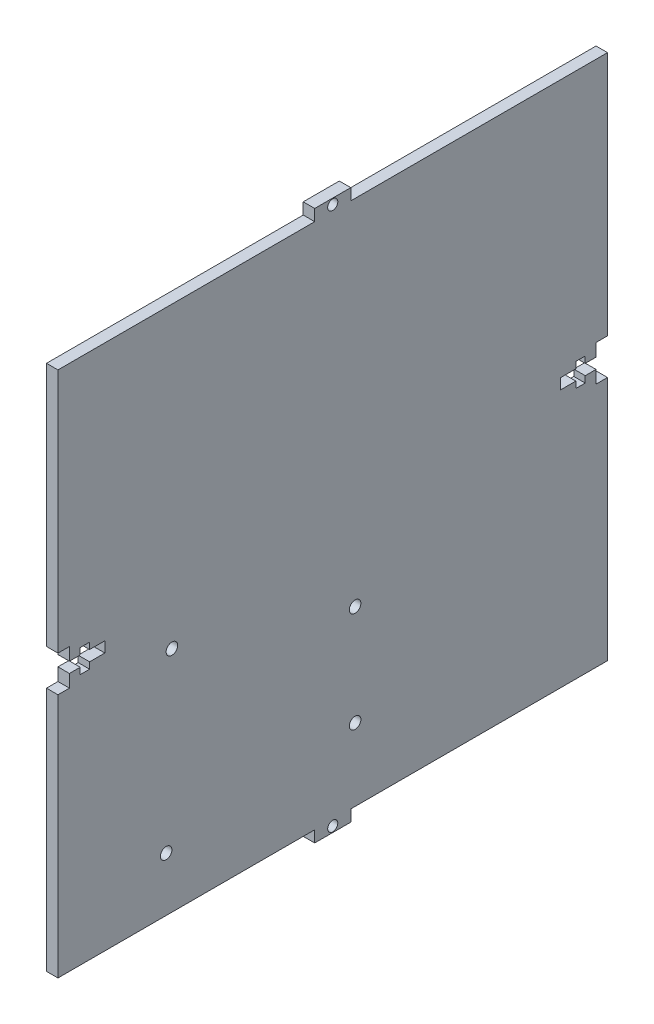
from build123d import *

# Parameters (mm, degrees)
SKETCH1_W           = 152.4
SKETCH1_H           = 146.04
BOSS_EXTRUDE1_DEPTH = 3.18
SKETCH3_R           = 1.4
SKETCH3_W           = 10
SKETCH3_H           = 3.18
BOSS_EXTRUDE5_DEPTH = 3.18
CUT_EXTRUDE2_DEPTH  = 4.18
CUT_EXTRUDE3_DEPTH  = 4.18
SKETCH6_R           = 1.6
CUT_EXTRUDE6_DEPTH  = 4.18


with BuildPart() as part:
    # Sketch1 → Boss-Extrude1 (new body)
    with BuildSketch(Plane(origin=(0, 0, 0), x_dir=(0, 0, -1), z_dir=(1, 0, 0))):
        Rectangle(SKETCH1_W, SKETCH1_H)
    extrude(amount=BOSS_EXTRUDE1_DEPTH)

    # Sketch3 → Boss-Extrude5 (add)
    with BuildSketch(Plane.ZY):
        Polygon((0, 73.02), (5, 73.02), (5, 76.2), (-5, 76.2), (-5, 73.02), align=None)
        with Locations((0, 74.61)):
            Circle(SKETCH3_R, mode=Mode.SUBTRACT)
        with Locations((0, -74.61)):
            Rectangle(SKETCH3_W, SKETCH3_H)
        with Locations((0, -74.61)):
            Circle(SKETCH3_R, mode=Mode.SUBTRACT)
    extrude(amount=-BOSS_EXTRUDE5_DEPTH)

    # Sketch4 → Cut-Extrude2 (cut, through all)
    with BuildSketch(Plane(origin=(0, 0, 0), x_dir=(0, 0, -1), z_dir=(1, 0, 0))):
        Polygon((-76.2, -5), (-76.2, 5), (-73.02, 5), (-73.02, 1.47), (-70.02, 1.47), (-70.02, 3.25), (-67.42, 3.25), (-67.42, 1.47), (-63.2, 1.47), (-63.2, -1.47), (-67.42, -1.47), (-67.42, -3.25), (-70.02, -3.25), (-70.02, -1.47), (-73.02, -1.47), (-73.02, -5), align=None)
    extrude(amount=CUT_EXTRUDE2_DEPTH, mode=Mode.SUBTRACT)

    # Sketch5 → Cut-Extrude3 (cut, through all)
    with BuildSketch(Plane.ZY):
        Polygon((-70.02, -1.47), (-73.02, -1.47), (-73.02, -5), (-76.2, -5), (-76.2, 5), (-73.02, 5), (-73.02, 1.47), (-70.02, 1.47), (-70.02, 3.25), (-67.42, 3.25), (-67.42, 1.47), (-63.2, 1.47), (-63.2, -1.47), (-67.42, -1.47), (-67.42, -3.25), (-70.02, -3.25), align=None)
    extrude(amount=-CUT_EXTRUDE3_DEPTH, mode=Mode.SUBTRACT)

    # Sketch6 → Cut-Extrude6 (cut, through all)
    with BuildSketch(Plane.ZY):
        with Locations((46.2, -58.02)):
            Circle(SKETCH6_R)
        with Locations((44.6, -9.72)):
            Circle(SKETCH6_R)
        with Locations((-6.2, -52.92)):
            Circle(SKETCH6_R)
        with Locations((-6.2, -25.02)):
            Circle(SKETCH6_R)
    extrude(amount=-CUT_EXTRUDE6_DEPTH, mode=Mode.SUBTRACT)


solid = part.part
